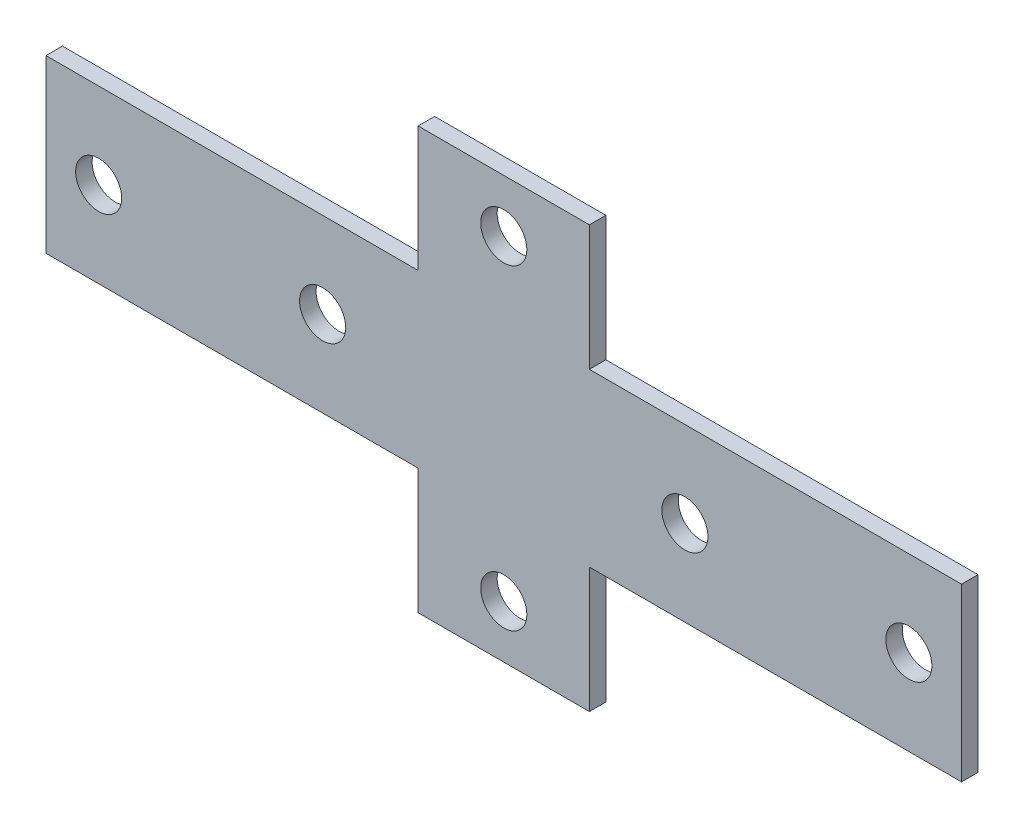
from build123d import *

# Parameters (mm, degrees)
SKETCH_1_R      = 3.5
EXTRUDE_1_DEPTH = 2.5


with BuildPart() as part:
    # Эскиз1 → Бобышка-Вытянуть1 (new body)
    with BuildSketch(Plane.XY):
        Polygon((13, -13), (69.5, -13), (69.5, 13), (13, 13), (13, 32), (-13, 32), (-13, 13), (-69.5, 13), (-69.5, -13), (-13, -13), (-13, -32), (13, -32), align=None)
        with Locations((0, 24)):
            Circle(SKETCH_1_R, mode=Mode.SUBTRACT)
        with Locations((0, -24)):
            Circle(SKETCH_1_R, mode=Mode.SUBTRACT)
        with Locations((-61.5, 0)):
            Circle(SKETCH_1_R, mode=Mode.SUBTRACT)
        with Locations((-27.5, 0)):
            Circle(SKETCH_1_R, mode=Mode.SUBTRACT)
        with Locations(Location((27.5, 0, 0), (0, 0, 180))):  # turned: the seam where the file's is
            Circle(SKETCH_1_R, mode=Mode.SUBTRACT)
        with Locations(Location((61.5, 0, 0), (0, 0, 180))):  # turned: the seam where the file's is
            Circle(SKETCH_1_R, mode=Mode.SUBTRACT)
    extrude(amount=EXTRUDE_1_DEPTH)


solid = part.part
